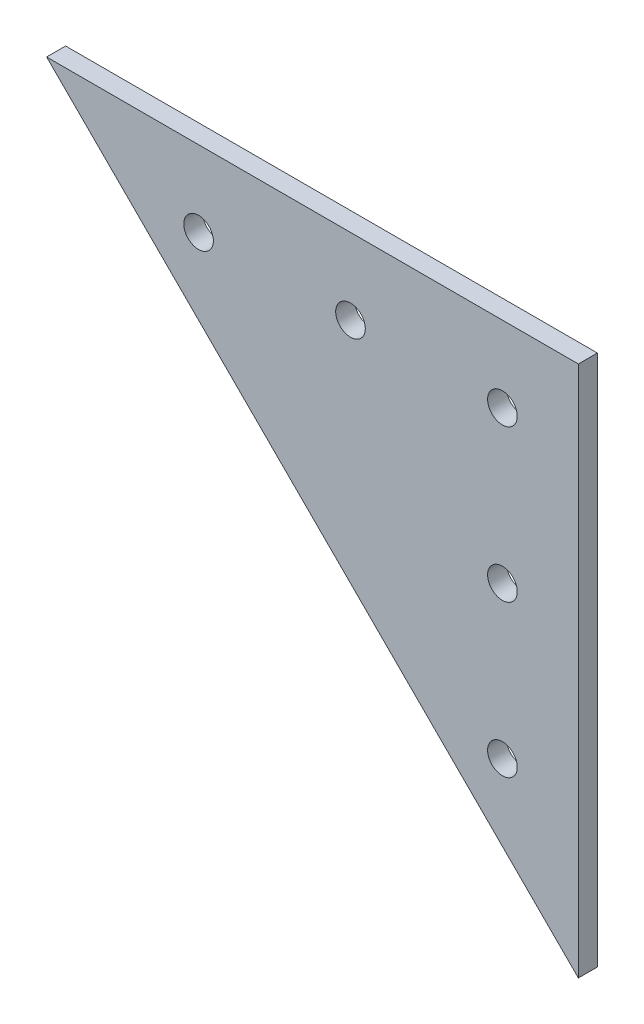
from build123d import *

# Parameters (mm, degrees)
SKETCH1_R           = 2.4765
BOSS_EXTRUDE1_DEPTH = 1.5875


with BuildPart() as part:
    # Sketch1 → Boss-Extrude1 (new body, symmetric)
    with BuildSketch(Plane.XY):
        Polygon((-44.45, 44.45), (44.45, 44.45), (44.45, -44.45), align=None)
        with Locations((6.35, 31.75)):
            Circle(SKETCH1_R, mode=Mode.SUBTRACT)
        with Locations((31.75, 31.75)):
            Circle(SKETCH1_R, mode=Mode.SUBTRACT)
        with Locations((31.75, 6.35)):
            Circle(SKETCH1_R, mode=Mode.SUBTRACT)
        with Locations((31.75, -19.05)):
            Circle(SKETCH1_R, mode=Mode.SUBTRACT)
        with Locations((-19.05, 31.75)):
            Circle(SKETCH1_R, mode=Mode.SUBTRACT)
    extrude(amount=BOSS_EXTRUDE1_DEPTH, both=True)


solid = part.part
